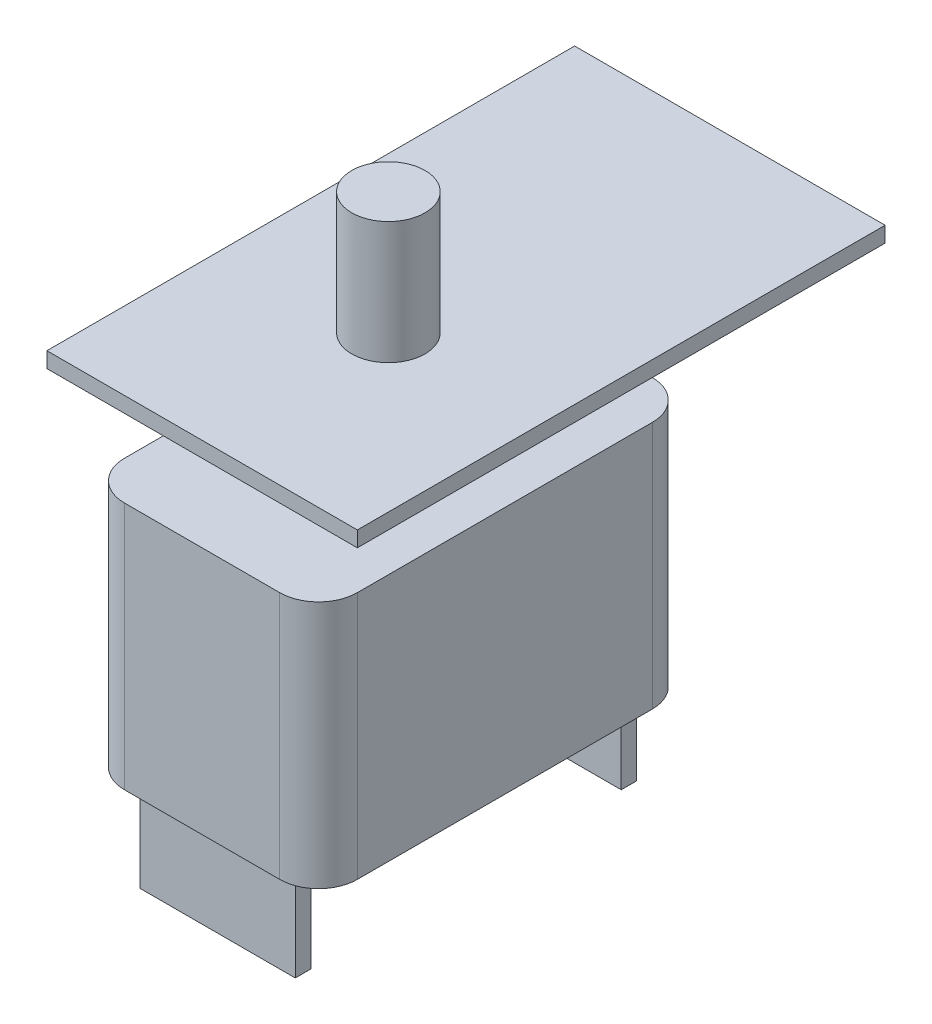
from build123d import *

# Parameters (mm, degrees)
SKETCH1_W           = 19.05
SKETCH1_H           = 30.48
BOSS_EXTRUDE1_DEPTH = 20.32
FILLET1_R           = 3.175
SKETCH2_R           = 6
BOSS_EXTRUDE2_DEPTH = 6.35
SKETCH3_W           = 12.7
SKETCH3_H           = 1.27
BOSS_EXTRUDE3_DEPTH = 7.62
SKETCH4_W           = 25.4
SKETCH4_H           = 43.18
BOSS_EXTRUDE4_DEPTH = 1.27
SKETCH5_R           = 3
BOSS_EXTRUDE5_DEPTH = 10


with BuildPart() as part:
    # Sketch1 → Boss-Extrude1 (new body)
    with BuildSketch(Plane(origin=(0, 0, 0), x_dir=(1, 0, 0), z_dir=(0, 1, 0))):
        Rectangle(SKETCH1_W, SKETCH1_H)
    extrude(amount=BOSS_EXTRUDE1_DEPTH)

    # Fillet1
    fillet1_edges = [part.edges().sort_by_distance(p)[0] for p in [
        (9.525, 10.16, 15.24),
        (-9.525, 10.16, 15.24),
        (-9.525, 10.16, -15.24),
        (9.525, 10.16, -15.24),
    ]]
    fillet(fillet1_edges, radius=FILLET1_R)

    # Sketch2 → Boss-Extrude2 (add)
    with BuildSketch(Plane(origin=(0, 20.32, 0), x_dir=(1, 0, 0), z_dir=(0, 1, 0))):
        Circle(SKETCH2_R)
    extrude(amount=BOSS_EXTRUDE2_DEPTH)

    # Sketch3 → Boss-Extrude3 (add)
    with BuildSketch(Plane.XZ):
        with Locations((0, 13.335)):
            Rectangle(SKETCH3_W, SKETCH3_H)
        with Locations((0, -13.335)):
            Rectangle(SKETCH3_W, SKETCH3_H)
    extrude(amount=BOSS_EXTRUDE3_DEPTH)

    # Sketch4 → Boss-Extrude4 (add)
    with BuildSketch(Plane(origin=(0, 26.67, 0), x_dir=(1, 0, 0), z_dir=(0, 1, 0))):
        with Locations((0, 6.35)):
            Rectangle(SKETCH4_W, SKETCH4_H)
    extrude(amount=BOSS_EXTRUDE4_DEPTH)

    # Sketch5 → Boss-Extrude5 (add)
    with BuildSketch(Plane(origin=(0, 27.94, 0), x_dir=(1, 0, 0), z_dir=(0, 1, 0))):
        Circle(SKETCH5_R)
    extrude(amount=BOSS_EXTRUDE5_DEPTH)


solid = part.part
